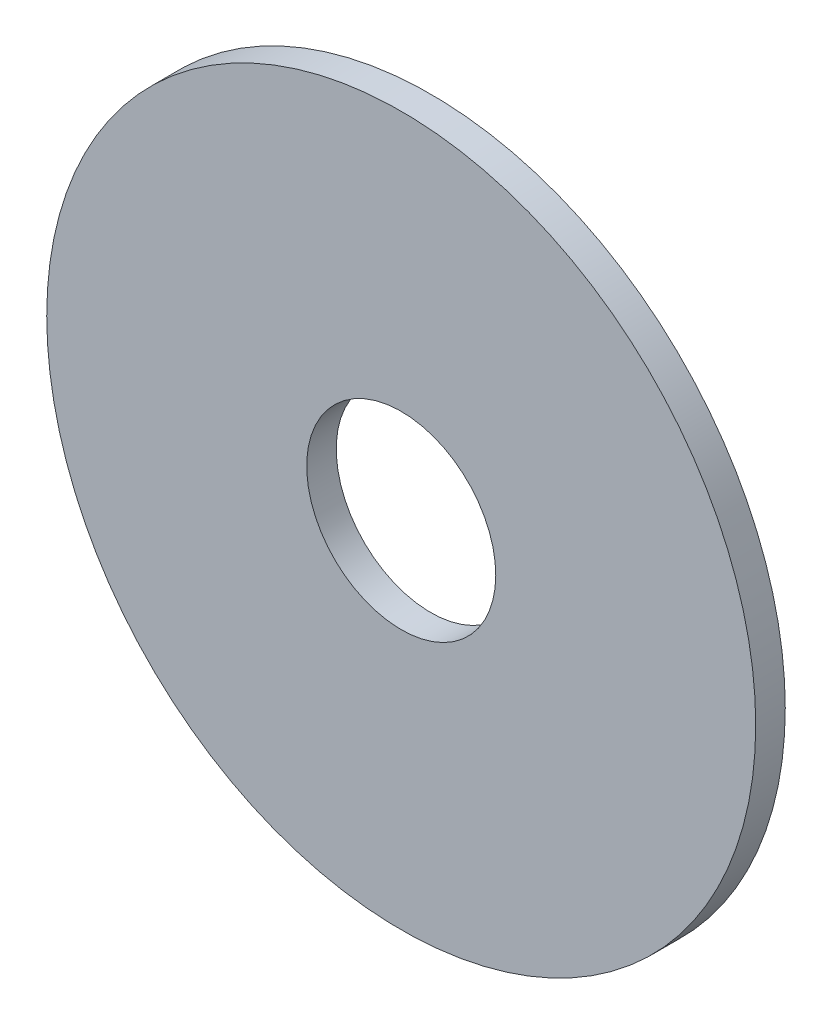
from build123d import *

# Parameters (mm, degrees)
SKETCH1_R           = 6
BOSS_EXTRUDE1_DEPTH = 0.5
SKETCH2_R           = 1.6
CUT_EXTRUDE1_DEPTH  = 0.5


with BuildPart() as part:
    # Sketch1 → Boss-Extrude1 (new body)
    with BuildSketch(Plane.XY):
        Circle(SKETCH1_R)
    extrude(amount=BOSS_EXTRUDE1_DEPTH)

    # Sketch2 → Cut-Extrude1 (cut)
    with BuildSketch(Plane.XY.offset(0.5)):
        Circle(SKETCH2_R)
    extrude(amount=-CUT_EXTRUDE1_DEPTH, mode=Mode.SUBTRACT)


solid = part.part
